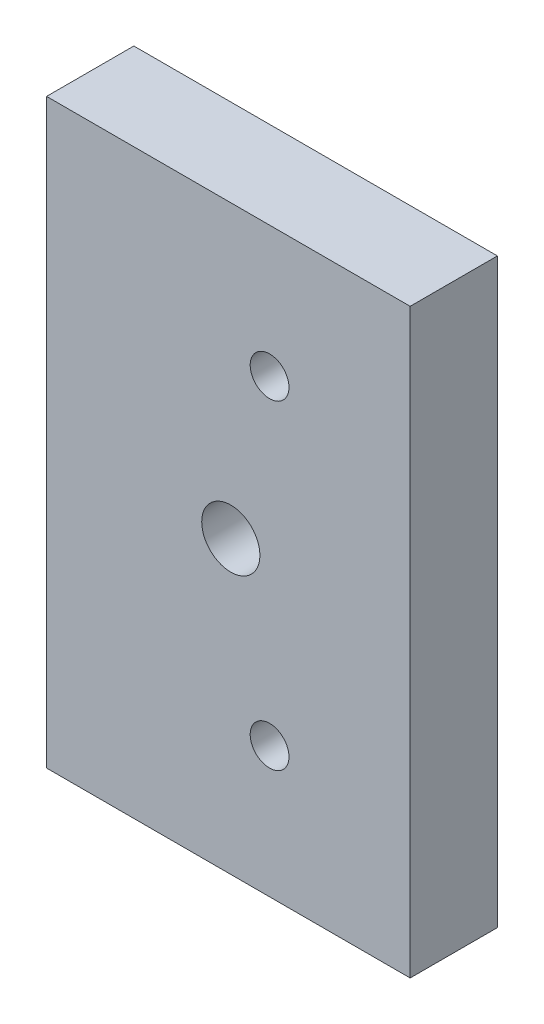
from build123d import *

# Parameters (mm, degrees)
SKETCH1_W             = 75
SKETCH1_H             = 120
SKETCH1_R             = 4
BOSS_EXTRUDE1_DEPTH   = 18
F_1_0MM_DOWEL_HOLE1_D = 12


with BuildPart() as part:
    # Sketch1 → Boss-Extrude1 (new body)
    with BuildSketch(Plane.XY):
        Rectangle(SKETCH1_W, SKETCH1_H)
        with Locations((8.5, 33)):
            Circle(SKETCH1_R, mode=Mode.SUBTRACT)
        with Locations((8.5, -33)):
            Circle(SKETCH1_R, mode=Mode.SUBTRACT)
    extrude(amount=BOSS_EXTRUDE1_DEPTH)

    # Ø1.0mm Dowel Hole1 (through all)
    with Locations(Plane(origin=(0, 0, 0), x_dir=(-1, 0, 0), z_dir=(0, 0, -1))):
        with Locations((-0.5, 0)):
            Hole(F_1_0MM_DOWEL_HOLE1_D / 2)


solid = part.part
